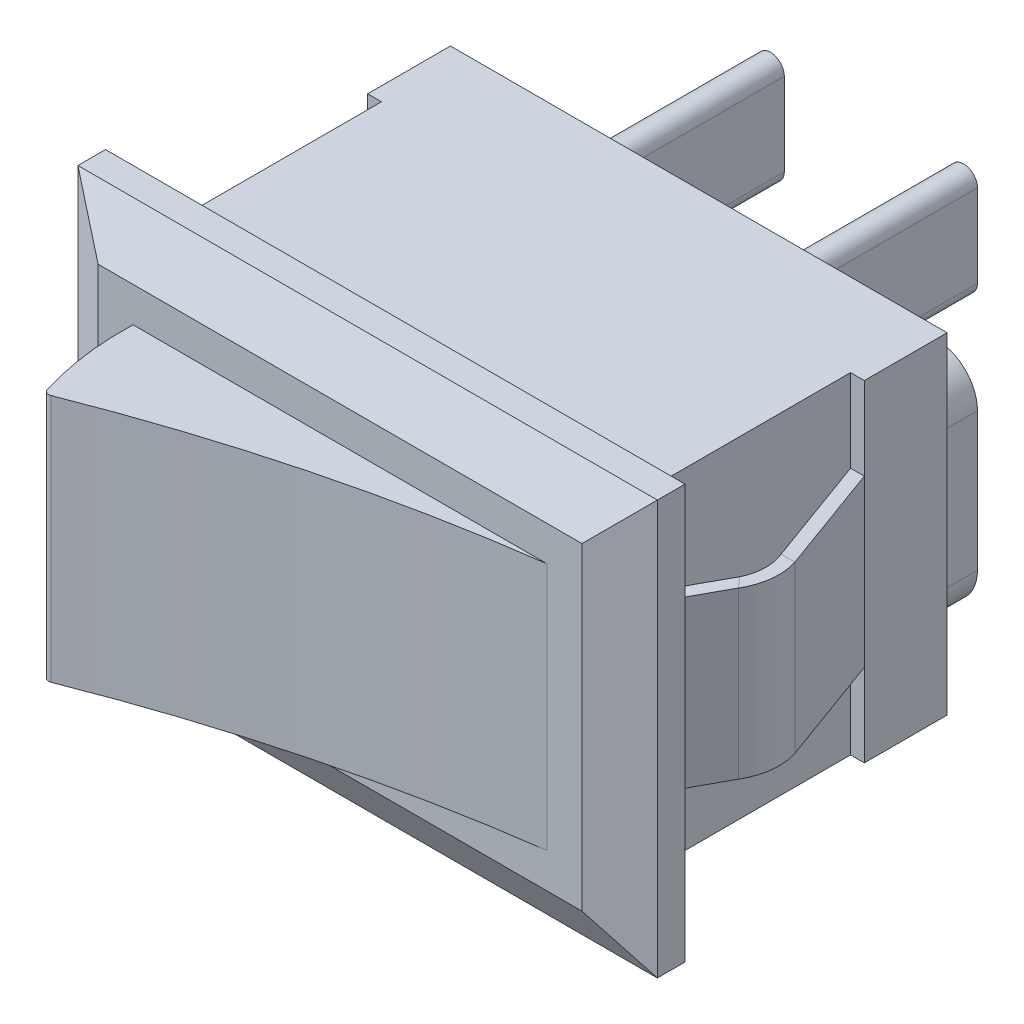
from build123d import *

# Parameters (mm, degrees)
SKETCH_1_W             = 21
SKETCH_1_H             = 15
EXTRUDE_1_DEPTH        = 17
SKETCH_3_OUTSIDE_W     = 29.18
SKETCH_3_OUTSIDE_H     = 23.18
SKETCH_3_OUTSIDE_W_2   = 18
SKETCH_3_OUTSIDE_H_2   = 12
CUT_EXTRUDE_1_DEPTH    = 11
SKETCH_4_OUTSIDE_W     = 29.18
SKETCH_4_OUTSIDE_H     = 23.18
SKETCH_4_OUTSIDE_W_2   = 15
SKETCH_4_OUTSIDE_H_2   = 9
CUT_EXTRUDE_2_DEPTH    = 4
CUT_EXTRUDE_3_REACH    = 14
CUT_EXTRUDE_4_REACH    = 14
FILLET_2_R             = 0.2
CHAMFER_1_SIZE         = 1
CHAMFER_1_SIZE2        = 1.732050808
CHAMFER_1_PART_2_SIZE  = 1
CHAMFER_1_PART_2_SIZE2 = 1.732050808
CHAMFER_1_PART_3_SIZE  = 1
CHAMFER_1_PART_3_SIZE2 = 1.732050808
CHAMFER_1_PART_4_SIZE  = 1
CHAMFER_1_PART_4_SIZE2 = 1.732050808
CUT_EXTRUDE_5_REACH    = 15.5
SKETCH_7_W             = 3.215432019
SKETCH_7_H             = 8
SKETCH_8_W             = 0.5
SKETCH_8_H             = 6
EXTRUDE_2_DEPTH        = 1.6
EXTRUDE_3_DEPTH        = 8
PATTERN_LINEAR_2_COUNT = 3
PATTERN_LINEAR_2_PITCH = 7
PATTERN_LINEAR_3_COUNT = 2
PATTERN_LINEAR_3_PITCH = 7


with BuildPart() as part:
    # 草图1 → 凸台-拉伸1 (new body)
    with BuildSketch(Plane.XY):
        with Locations((10.5, 7.5)):
            Rectangle(SKETCH_1_W, SKETCH_1_H)
    extrude(amount=EXTRUDE_1_DEPTH)

    # 草图3 outside → 切除-拉伸1 (cut)
    with BuildSketch(Plane(origin=(0, 0, 0), x_dir=(-1, 0, 0), z_dir=(0, 0, -1))):
        with Locations((-10.5, 7.5)):
            Rectangle(SKETCH_3_OUTSIDE_W, SKETCH_3_OUTSIDE_H)
        with Locations((-10.5, 7.5)):
            Rectangle(SKETCH_3_OUTSIDE_W_2, SKETCH_3_OUTSIDE_H_2, mode=Mode.SUBTRACT)
    extrude(amount=-CUT_EXTRUDE_1_DEPTH, mode=Mode.SUBTRACT)

    # 草图4 outside → 切除-拉伸2 (cut)
    with BuildSketch(Plane.XY.offset(17)):
        with Locations((10.5, 7.5)):
            Rectangle(SKETCH_4_OUTSIDE_W, SKETCH_4_OUTSIDE_H)
        with Locations((10.5, 7.5)):
            Rectangle(SKETCH_4_OUTSIDE_W_2, SKETCH_4_OUTSIDE_H_2, mode=Mode.SUBTRACT)
    extrude(amount=-CUT_EXTRUDE_2_DEPTH, mode=Mode.SUBTRACT)

    # 草图5 → 切除-拉伸3 (cut, up to next)
    with BuildSketch(Plane.XZ.offset(-3), mode=Mode.PRIVATE) as cut_extrude_3_sk1:
        with BuildLine():
            Line((3, 17), (3.786081295, 18.926671419))
            Line((3.786081295, 18.926671419), (19.848042348, 18.643435221))
            Line((19.848042348, 18.643435221), (18, 13))
            ThreePointArc((18, 13), (10.37304874, 14.523932773), (3, 17))
        make_face()
    cut_extrude_3_tool1 = extrude(cut_extrude_3_sk1.sketch, amount=-CUT_EXTRUDE_3_REACH, mode=Mode.PRIVATE) & part.part
    add(cut_extrude_3_tool1.solids().sort_by_distance((12.266887, 3, 16.568518))[0], mode=Mode.SUBTRACT)

    # 草图6 → 切除-拉伸4 (cut, up to next)
    with BuildSketch(Plane.XZ.offset(-3), mode=Mode.PRIVATE) as cut_extrude_4_sk1:
        with BuildLine():
            Line((3.538726555, 16.783166359), (1.834472807, 18.259535343))
            Line((1.834472807, 18.259535343), (1.834472807, 13.545763946))
            Line((1.834472807, 13.545763946), (3, 13))
            ThreePointArc((3, 13), (3.102200266, 14.915387354), (3.538726555, 16.783166359))
        make_face()
    cut_extrude_4_tool1 = extrude(cut_extrude_4_sk1.sketch, amount=-CUT_EXTRUDE_4_REACH, mode=Mode.PRIVATE) & part.part
    add(cut_extrude_4_tool1.solids().sort_by_distance((2.498394, 3, 15.595743))[0], mode=Mode.SUBTRACT)

    # 圆角2
    fillet_2_edges = [part.edges().sort_by_distance(p)[0] for p in [
        (3.538726555, 7.5, 16.783166359),
    ]]
    fillet(fillet_2_edges, radius=FILLET_2_R)

    # 倒角1
    chamfer_1_edges = [part.edges().sort_by_distance(p)[0] for p in [
        (10.5, 15, 13),
    ]]
    chamfer_1_side = [part.faces().sort_by_distance(p)[0] for p in [
        (10.5, 15, 12),
    ]]
    chamfer(chamfer_1_edges, length=CHAMFER_1_SIZE, length2=CHAMFER_1_SIZE2, reference=chamfer_1_side[0])

    # 倒角1 part 2
    chamfer_1_part_2_edges = [part.edges().sort_by_distance(p)[0] for p in [
        (0, 7.5, 13),
    ]]
    chamfer_1_part_2_side = [part.faces().sort_by_distance(p)[0] for p in [
        (0, 7.5, 12),
    ]]
    chamfer(chamfer_1_part_2_edges, length=CHAMFER_1_PART_2_SIZE, length2=CHAMFER_1_PART_2_SIZE2, reference=chamfer_1_part_2_side[0])

    # 倒角1 part 3
    chamfer_1_part_3_edges = [part.edges().sort_by_distance(p)[0] for p in [
        (10.5, 0, 13),
    ]]
    chamfer_1_part_3_side = [part.faces().sort_by_distance(p)[0] for p in [
        (10.5, 0, 12),
    ]]
    chamfer(chamfer_1_part_3_edges, length=CHAMFER_1_PART_3_SIZE, length2=CHAMFER_1_PART_3_SIZE2, reference=chamfer_1_part_3_side[0])

    # 倒角1 part 4
    chamfer_1_part_4_edges = [part.edges().sort_by_distance(p)[0] for p in [
        (21, 7.5, 13),
    ]]
    chamfer_1_part_4_side = [part.faces().sort_by_distance(p)[0] for p in [
        (21, 7.5, 12),
    ]]
    chamfer(chamfer_1_part_4_edges, length=CHAMFER_1_PART_4_SIZE, length2=CHAMFER_1_PART_4_SIZE2, reference=chamfer_1_part_4_side[0])

    # 草图7 → 切除-拉伸5 (cut, up to next)
    with BuildSketch(Plane.XZ.offset(-1.5), mode=Mode.PRIVATE) as cut_extrude_5_sk1:
        with Locations((0.39228399, 7)):
            Rectangle(SKETCH_7_W, SKETCH_7_H)
    cut_extrude_5_tool1 = extrude(cut_extrude_5_sk1.sketch, amount=-CUT_EXTRUDE_5_REACH, mode=Mode.PRIVATE) & part.part
    add(cut_extrude_5_tool1.solids().sort_by_distance((0.392284, 1.5, 7))[0], mode=Mode.SUBTRACT)
    # 草图7 → 切除-拉伸5 (cut, up to next)
    with BuildSketch(Plane.XZ.offset(-1.5), mode=Mode.PRIVATE) as cut_extrude_5_sk2:
        with Locations((20.60771601, 7)):
            Rectangle(SKETCH_7_W, SKETCH_7_H)
    cut_extrude_5_tool2 = extrude(cut_extrude_5_sk2.sketch, amount=-CUT_EXTRUDE_5_REACH, mode=Mode.PRIVATE) & part.part
    add(cut_extrude_5_tool2.solids().sort_by_distance((20.607716, 1.5, 7))[0], mode=Mode.SUBTRACT)

    # 扫描1: sweep along a path in 草图9
    with BuildLine(Plane(origin=(0, 7.5, 0), x_dir=(-1, 0, 0), z_dir=(0, -1, 0))) as sweep_1_path:
        Line((-1.75, -3), (-0.309821019, -6.95685923))
        ThreePointArc((-0.309821019, -6.95685923), (-0.195012991, -7.793192673), (-0.4354877, -8.602393776))
        Line((-0.4354877, -8.602393776), (-1.75, -11))
    # 草图8 → 扫描1 (sweep)
    with BuildSketch(Plane.XY.offset(3)):
        with Locations((1.75, 7.5)):
            Rectangle(SKETCH_8_W, SKETCH_8_H)
    sweep_1 = sweep(path=sweep_1_path.line)

    # 镜向1: 扫描1 across plane
    add(sweep_1.mirror(Plane(origin=(10.5, 0, 0), x_dir=(0, 0, 1), z_dir=(1, 0, 0))))

    # 草图10 → 凸台-拉伸2 (add)
    with BuildSketch(Plane(origin=(0, 0, 0), x_dir=(-1, 0, 0), z_dir=(0, 0, -1))):
        with BuildLine():
            Line((-5, 5), (-5, 10))
            ThreePointArc((-5, 10), (-3.5, 11.5), (-2, 10))
            Line((-2, 10), (-2, 5))
            ThreePointArc((-2, 5), (-3.5, 3.5), (-5, 5))
        make_face()
    extrude_2 = extrude(amount=EXTRUDE_2_DEPTH)

    # 草图11 → 凸台-拉伸3 (add)
    with BuildSketch(Plane(origin=(0, 0, -1.6), x_dir=(-1, 0, 0), z_dir=(0, 0, -1))):
        with BuildLine():
            Line((-4, 6), (-4, 9))
            ThreePointArc((-4, 9), (-3.5, 9.5), (-3, 9))
            Line((-3, 9), (-3, 6))
            ThreePointArc((-3, 6), (-3.5, 5.5), (-4, 6))
        make_face()
    extrude_3 = extrude(amount=EXTRUDE_3_DEPTH)

    # 阵列(线性)2: 凸台-拉伸2 ×3
    with Locations(*[(i * PATTERN_LINEAR_2_PITCH, 0, 0) for i in range(1, PATTERN_LINEAR_2_COUNT)]):
        add(extrude_2)

    # 阵列(线性)3: 凸台-拉伸3 ×2
    with Locations(*[(i * PATTERN_LINEAR_3_PITCH, 0, 0) for i in range(1, PATTERN_LINEAR_3_COUNT)]):
        add(extrude_3)


solid = part.part
